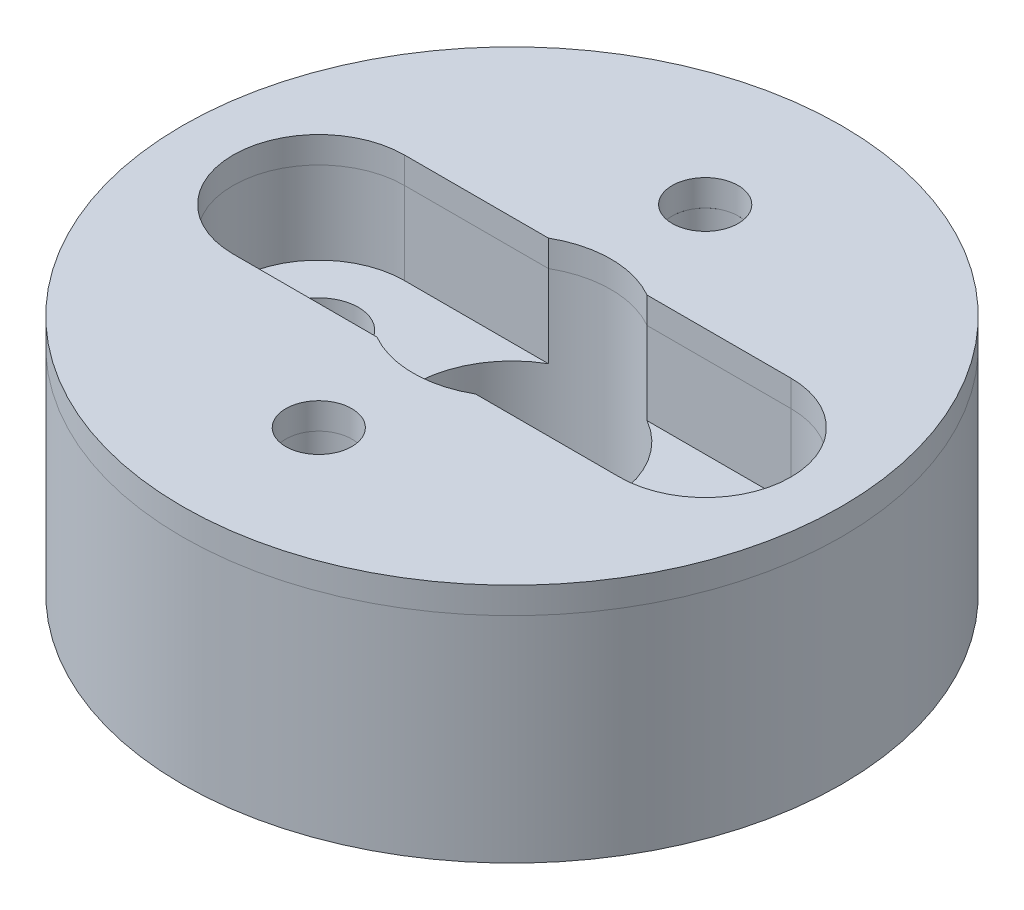
from build123d import *

# Parameters (mm, degrees)
SKETCH1_R           = 12.7
SKETCH1_R_2         = 1.524
BOSS_EXTRUDE1_DEPTH = 8.255
SKETCH2_R           = 3.302
CUT_EXTRUDE_R_DEPTH = 3.175
SKETCH3_R           = 1.27
CUT_EXTRUDE2_DEPTH  = 9.255
SKETCH4_R           = 3.81
CUT_EXTRUDE3_DEPTH  = 9.255
CUT_EXTRUDE4_DEPTH  = 3.175
SKETCH6_R           = 12.7
SKETCH6_R_2         = 1.27
EXTRA_HEIGHT_DEPTH  = 1.016


with BuildPart() as part:
    # Sketch1 → Boss-Extrude1 (new body)
    with BuildSketch(Plane(origin=(0, 0, 0), x_dir=(1, 0, 0), z_dir=(0, 1, 0))):
        Circle(SKETCH1_R)
        with Locations((7.4422, 0)):
            Circle(SKETCH1_R_2, mode=Mode.SUBTRACT)
        with Locations((-7.4422, 0)):
            Circle(SKETCH1_R_2, mode=Mode.SUBTRACT)
    extrude(amount=BOSS_EXTRUDE1_DEPTH)

    # Sketch2 → Cut-Extrude r (cut)
    with BuildSketch(Plane(origin=(0, 8.255, 0), x_dir=(1, 0, 0), z_dir=(0, 1, 0))):
        with Locations((-7.4422, 0)):
            Circle(SKETCH2_R)
        with Locations((7.4422, 0)):
            Circle(SKETCH2_R)
    extrude(amount=-CUT_EXTRUDE_R_DEPTH, mode=Mode.SUBTRACT)

    # Sketch3 → Cut-Extrude2 (cut, through all)
    with BuildSketch(Plane(origin=(0, 8.255, 0), x_dir=(1, 0, 0), z_dir=(0, 1, 0))):
        with Locations((0, -7.4422)):
            Circle(SKETCH3_R)
        with Locations((0, 7.4422)):
            Circle(SKETCH3_R)
    extrude(amount=-CUT_EXTRUDE2_DEPTH, mode=Mode.SUBTRACT)

    # Sketch4 → Cut-Extrude3 (cut, through all)
    with BuildSketch(Plane(origin=(0, 8.255, 0), x_dir=(1, 0, 0), z_dir=(0, 1, 0))):
        Circle(SKETCH4_R)
    extrude(amount=-CUT_EXTRUDE3_DEPTH, mode=Mode.SUBTRACT)

    # Sketch5 → Cut-Extrude4 (cut)
    with BuildSketch(Plane(origin=(0, 8.255, 0), x_dir=(1, 0, 0), z_dir=(0, 1, 0))):
        with BuildLine():
            Line((-7.4422, 3.302), (7.4422, 3.302))
            ThreePointArc((7.4422, 3.302), (10.7442, 0), (7.4422, -3.302))
            Line((7.4422, -3.302), (-7.4422, -3.302))
            ThreePointArc((-7.4422, -3.302), (-10.7442, 0), (-7.4422, 3.302))
        make_face()
    extrude(amount=-CUT_EXTRUDE4_DEPTH, mode=Mode.SUBTRACT)


with BuildPart() as body_2:
    # Sketch6 → Extra_Height (new body)
    with BuildSketch(Plane(origin=(0, 8.255, 0), x_dir=(1, 0, 0), z_dir=(0, 1, 0))):
        Circle(SKETCH6_R)
        with Locations((0, -7.4422)):
            Circle(SKETCH6_R_2, mode=Mode.SUBTRACT)
        with Locations((0, 7.4422)):
            Circle(SKETCH6_R_2, mode=Mode.SUBTRACT)
        with BuildLine():
            Line((-1.900761952, 3.302), (-7.4422, 3.302))
            ThreePointArc((-7.4422, 3.302), (-10.7442, 0), (-7.4422, -3.302))
            Line((-7.4422, -3.302), (-1.900761952, -3.302))
            ThreePointArc((-1.900761952, -3.302), (0, -3.81), (1.900761952, -3.302))
            Line((1.900761952, -3.302), (7.4422, -3.302))
            ThreePointArc((7.4422, -3.302), (10.7442, 0), (7.4422, 3.302))
            Line((7.4422, 3.302), (1.900761952, 3.302))
            ThreePointArc((1.900761952, 3.302), (0, 3.81), (-1.900761952, 3.302))
        make_face(mode=Mode.SUBTRACT)
    extrude(amount=EXTRA_HEIGHT_DEPTH)


solid = Compound([part.part, body_2.part])
